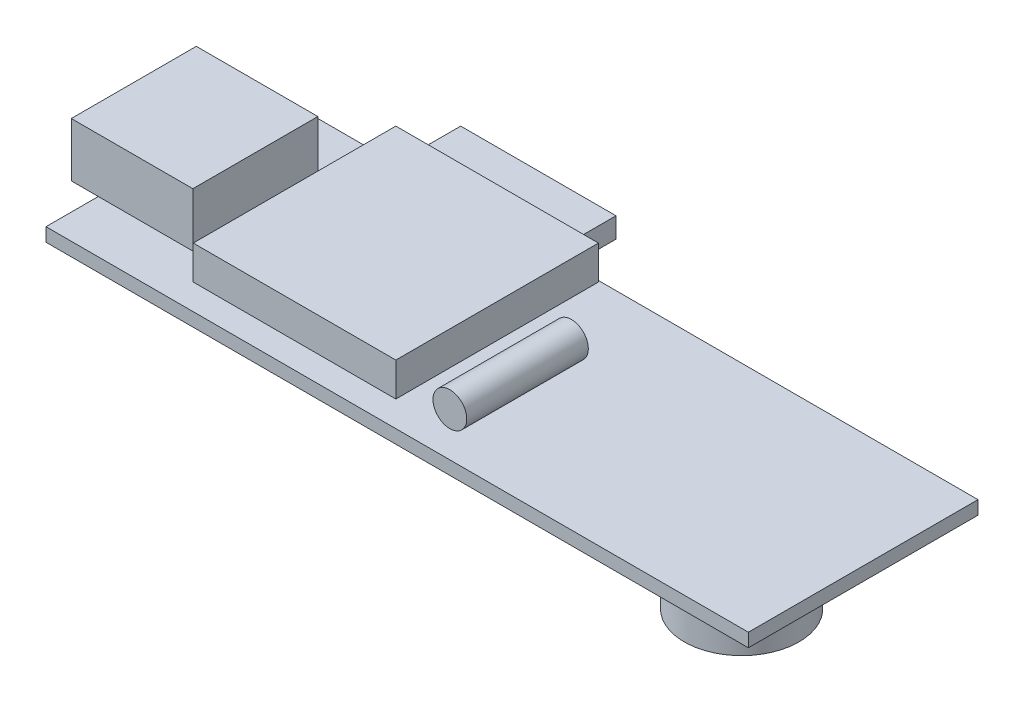
from build123d import *

# Parameters (mm, degrees)
SKETCH1_W           = 52
SKETCH1_H           = 17
BOSS_EXTRUDE1_DEPTH = 1
SKETCH2_W           = 2
SKETCH2_H           = 9.255511068
SKETCH2_W_2         = 7
BOSS_EXTRUDE2_DEPTH = 4
SKETCH3_W           = 15
SKETCH3_H           = 15
BOSS_EXTRUDE3_DEPTH = 2.5
SKETCH4_W           = 11.5
SKETCH4_H           = 1.5
BOSS_EXTRUDE4_DEPTH = 2.5
SKETCH5_R           = 1.25
BOSS_EXTRUDE5_DEPTH = 9
SKETCH6_W           = 8.5
SKETCH6_H           = 8.5
BOSS_EXTRUDE6_DEPTH = 3.5
SKETCH7_R           = 4.25
BOSS_EXTRUDE7_DEPTH = 3
SKETCH8_W           = 11.544073995
SKETCH8_H           = 8.858488223
BOSS_EXTRUDE8_DEPTH = 2


with BuildPart() as part:
    # Sketch1 → Boss-Extrude1 (new body)
    with BuildSketch(Plane(origin=(0, 0, 0), x_dir=(1, 0, 0), z_dir=(0, 1, 0))):
        with Locations((-494, 281.751572327)):
            Rectangle(SKETCH1_W, SKETCH1_H)
    extrude(amount=BOSS_EXTRUDE1_DEPTH)

    # Sketch2 → Boss-Extrude2 (add)
    with BuildSketch(Plane(origin=(0, 1, 0), x_dir=(1, 0, 0), z_dir=(0, 1, 0))):
        with Locations((-521, 281.751572327)):
            Rectangle(SKETCH2_W, SKETCH2_H)
        with Locations((-516.5, 281.751572327)):
            Rectangle(SKETCH2_W_2, SKETCH2_H)
    extrude(amount=BOSS_EXTRUDE2_DEPTH)

    # Sketch3 → Boss-Extrude3 (add)
    with BuildSketch(Plane(origin=(0, 1, 0), x_dir=(1, 0, 0), z_dir=(0, 1, 0))):
        with Locations((-503.5, 282.651572327)):
            Rectangle(SKETCH3_W, SKETCH3_H)
    extrude(amount=BOSS_EXTRUDE3_DEPTH)

    # Sketch4 → Boss-Extrude4 (add)
    with BuildSketch(Plane(origin=(0, 0, -290.151572327), x_dir=(-1, 0, 0), z_dir=(0, 0, -1))):
        with Locations((502.95, 2.65)):
            Rectangle(SKETCH4_W, SKETCH4_H)
    extrude(amount=BOSS_EXTRUDE4_DEPTH)

    # Sketch6 → Boss-Extrude6 (add)
    with BuildSketch(Plane.XZ):
        with Locations((-477.25, -282.001572327)):
            Rectangle(SKETCH6_W, SKETCH6_H)
    extrude(amount=BOSS_EXTRUDE6_DEPTH)

    # Sketch7 → Boss-Extrude7 (add)
    with BuildSketch(Plane.XZ.offset(3.5)):
        with Locations((-477.25, -282.001572327)):
            Circle(SKETCH7_R)
    extrude(amount=BOSS_EXTRUDE7_DEPTH)

    # Sketch8 → Boss-Extrude8 (add)
    with BuildSketch(Plane(origin=(0, 0, 0), x_dir=(-1, 0, 0), z_dir=(0, -1, 0))):
        with Locations((497.867789367, 281.677075186)):
            Rectangle(SKETCH8_W, SKETCH8_H)
    extrude(amount=BOSS_EXTRUDE8_DEPTH)


with BuildPart() as body_2:
    # Sketch5 → Boss-Extrude5 (new body)
    with BuildSketch(Plane.XY.offset(-275.151572327)):
        with Locations((-492, 2.35)):
            Circle(SKETCH5_R)
    extrude(amount=-BOSS_EXTRUDE5_DEPTH)


solid = Compound([part.part, body_2.part])
